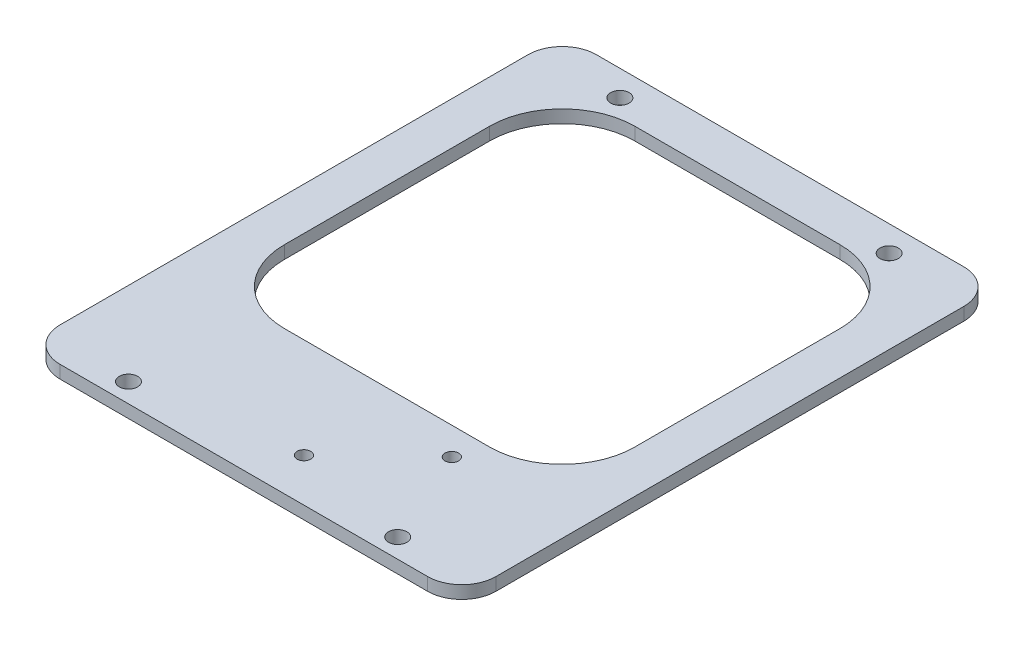
from build123d import *

# Parameters (mm, degrees)
SKETCH1_R           = 2.15
BOSS_EXTRUDE1_DEPTH = 3
CUT_EXTRUDE1_REACH  = 5
CUT_EXTRUDE2_REACH  = 5
SKETCH5_R           = 1.6


with BuildPart() as part:
    # Sketch1 → Boss-Extrude1 (new body)
    with BuildSketch(Plane(origin=(0, 0, 0), x_dir=(1, 0, 0), z_dir=(0, 1, 0))):
        with BuildLine():
            Line((-43, 51), (43, 51))
            ThreePointArc((43, 51), (48.656854249, 48.656854249), (51, 43))
            Line((51, 43), (51, -66.5))
            ThreePointArc((51, -66.5), (48.656854249, -72.156854249), (43, -74.5))
            Line((43, -74.5), (-43, -74.5))
            ThreePointArc((-43, -74.5), (-48.656854249, -72.156854249), (-51, -66.5))
            Line((-51, -66.5), (-51, 43))
            ThreePointArc((-51, 43), (-48.656854249, 48.656854249), (-43, 51))
        make_face()
        with Locations((-31.5, 45)):
            Circle(SKETCH1_R, mode=Mode.SUBTRACT)
        with Locations((31.5, 45)):
            Circle(SKETCH1_R, mode=Mode.SUBTRACT)
        with Locations((-31.5, -70)):
            Circle(SKETCH1_R, mode=Mode.SUBTRACT)
        with Locations((31.5, -70)):
            Circle(SKETCH1_R, mode=Mode.SUBTRACT)
    extrude(amount=BOSS_EXTRUDE1_DEPTH)

    # Sketch3 → Cut-Extrude1 (cut, up to next)
    with BuildSketch(Plane(origin=(0, 3, 0), x_dir=(1, 0, 0), z_dir=(0, 1, 0)), mode=Mode.PRIVATE) as cut_extrude1_sk1:
        with BuildLine():
            Line((-24, -41), (24, -41))
            ThreePointArc((24, -41), (36.02081528, -36.02081528), (41, -24))
            Line((41, -24), (41, 24))
            ThreePointArc((41, 24), (36.02081528, 36.02081528), (24, 41))
            Line((24, 41), (-24, 41))
            ThreePointArc((-24, 41), (-36.02081528, 36.02081528), (-41, 24))
            Line((-41, 24), (-41, -24))
            ThreePointArc((-41, -24), (-36.02081528, -36.02081528), (-24, -41))
        make_face()
    cut_extrude1_tool1 = extrude(cut_extrude1_sk1.sketch, amount=-CUT_EXTRUDE1_REACH, mode=Mode.PRIVATE) & part.part
    add(cut_extrude1_tool1.solids().sort_by_distance((0, 3, 0))[0], mode=Mode.SUBTRACT)

    # Sketch5 → Cut-Extrude2 (cut, up to next)
    with BuildSketch(Plane(origin=(0, 3, 0), x_dir=(1, 0, 0), z_dir=(0, 1, 0)), mode=Mode.PRIVATE) as cut_extrude2_sk1:
        with Locations((21.612877951, -47.443396553)):
            Circle(SKETCH5_R)
    cut_extrude2_tool1 = extrude(cut_extrude2_sk1.sketch, amount=-CUT_EXTRUDE2_REACH, mode=Mode.PRIVATE) & part.part
    add(cut_extrude2_tool1.solids().sort_by_distance((21.612878, 3, 47.443397))[0], mode=Mode.SUBTRACT)
    # Sketch5 → Cut-Extrude2 (cut, up to next)
    with BuildSketch(Plane(origin=(0, 3, 0), x_dir=(1, 0, 0), z_dir=(0, 1, 0)), mode=Mode.PRIVATE) as cut_extrude2_sk2:
        with Locations((3.957960008, -64.39137202)):
            Circle(SKETCH5_R)
    cut_extrude2_tool2 = extrude(cut_extrude2_sk2.sketch, amount=-CUT_EXTRUDE2_REACH, mode=Mode.PRIVATE) & part.part
    add(cut_extrude2_tool2.solids().sort_by_distance((3.95796, 3, 64.391372))[0], mode=Mode.SUBTRACT)


solid = part.part
